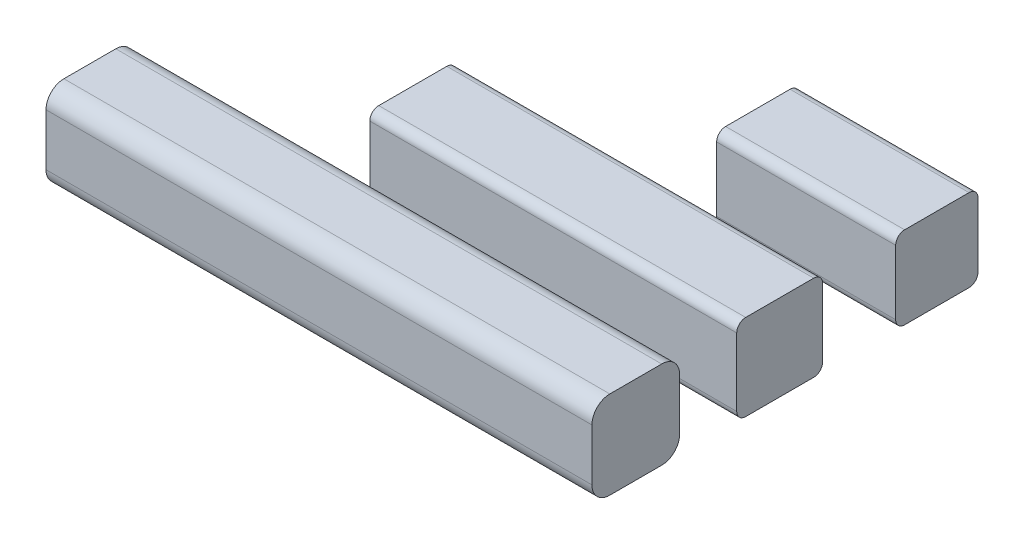
from build123d import *

# Parameters (mm, degrees)
SKETCH_1_R          = 4.9
SKETCH_1_W          = 5
SKETCH_1_H          = 5
EXTRUDE_1_DEPTH     = 5
SKETCH_2_W          = 10
SKETCH_2_H          = 5
EXTRUDE_2_DEPTH     = 5
SKETCH_3_R          = 5.914940822
CUT_EXTRUDE_1_DEPTH = 10
CUT_EXTRUDE_2_DEPTH = 10
SKETCH_5_W          = 4.8
SKETCH_5_H          = 4.8
EXTRUDE_3_DEPTH     = 10
SKETCH_5_W_2        = 4.6
SKETCH_5_H_2        = 4.6
EXTRUDE_3_2_DEPTH   = 10
SKETCH_5_W_3        = 4.5
SKETCH_5_H_3        = 4.5
EXTRUDE_3_3_DEPTH   = 10
FILLET_1_R          = 0.5
FILLET_2_R          = 0.5
FILLET_3_R          = 0.5
FILLET_4_R          = 0.5
SKETCH_6_W          = 4.9
SKETCH_6_H          = 4.9
EXTRUDE_4_DEPTH     = 20.5
FILLET_5_R          = 1
EXTRUDE_5_DEPTH     = 10.5
SKETCH_9_R          = 3.402598628
CUT_EXTRUDE_3_DEPTH = 10.5


with BuildPart() as part:
    # 草图1 → 凸台-拉伸1 (new body)
    with BuildSketch(Plane(origin=(0, 0, 0), x_dir=(1, 0, 0), z_dir=(0, 1, 0))):
        with Locations((-9.777161154, 17.932244479)):
            Circle(SKETCH_1_R)
        with Locations((-9.777161154, 17.932244479)):
            Rectangle(SKETCH_1_W, SKETCH_1_H, mode=Mode.SUBTRACT)
    extrude(amount=EXTRUDE_1_DEPTH)

    # 草图3 → 切除-拉伸1 (cut)
    with BuildSketch(Plane(origin=(0, 5, 0), x_dir=(1, 0, 0), z_dir=(0, 1, 0))):
        with Locations((-9.777161154, 17.932244479)):
            Circle(SKETCH_3_R)
    extrude(amount=-CUT_EXTRUDE_1_DEPTH, mode=Mode.SUBTRACT)


with BuildPart() as body_2:
    # 草图2 → 凸台-拉伸2 (new body)
    with BuildSketch(Plane(origin=(0, 0, 0), x_dir=(1, 0, 0), z_dir=(0, 1, 0))):
        with Locations((-15.49352073, 27.026927295)):
            Rectangle(SKETCH_2_W, SKETCH_2_H)
    extrude(amount=EXTRUDE_2_DEPTH)

    # 草图4 → 切除-拉伸2 (cut)
    with BuildSketch(Plane.ZY.offset(20.49352073)):
        Polygon((-29.526927295, 4.9), (-29.526927295, 5), (-24.526927295, 5), (-24.526927295, 0), (-24.626927295, 0), (-24.626927295, 4.9), align=None)
    extrude(amount=-CUT_EXTRUDE_2_DEPTH, mode=Mode.SUBTRACT)

    # 圆角1
    fillet_1_edges = [body_2.edges().sort_by_distance(p)[0] for p in [
        (-15.49352073, 0, -24.626927295),
        (-15.49352073, 4.9, -24.626927295),
        (-15.49352073, 4.9, -29.526927295),
        (-15.49352073, 0, -29.526927295),
    ]]
    fillet(fillet_1_edges, radius=FILLET_1_R)

    # 草图6 → 凸台-拉伸4 (add)
    with BuildSketch(Plane(origin=(-10.49352073, 0, 0), x_dir=(0, 0, -1), z_dir=(1, 0, 0))):
        with Locations((27.076927295, 2.45)):
            Rectangle(SKETCH_6_W, SKETCH_6_H)
    extrude(amount=EXTRUDE_4_DEPTH)

    # 圆角5
    fillet_5_edges = [body_2.edges().sort_by_distance(p)[0] for p in [
        (-0.24352073, 0, -24.626927295),
        (-0.24352073, 0, -29.526927295),
        (-0.24352073, 4.9, -29.526927295),
        (-0.24352073, 4.9, -24.626927295),
    ]]
    fillet(fillet_5_edges, radius=FILLET_5_R)


with BuildPart() as body_2_2:
    # 草图5 → 凸台-拉伸3 (new body)
    with BuildSketch(Plane(origin=(0, 0, 0), x_dir=(0, 0, -1), z_dir=(1, 0, 0))):
        with Locations((35.124788923, 2.4)):
            Rectangle(SKETCH_5_W, SKETCH_5_H)
    extrude(amount=EXTRUDE_3_DEPTH)

    # 圆角2
    fillet_2_edges = [body_2_2.edges().sort_by_distance(p)[0] for p in [
        (5, 4.8, -32.724788923),
        (5, 4.8, -37.524788923),
        (5, 0, -37.524788923),
        (5, 0, -32.724788923),
    ]]
    fillet(fillet_2_edges, radius=FILLET_2_R)

    # 草图8 → 凸台-拉伸5 (add)
    with BuildSketch(Plane.ZY):
        with BuildLine():
            Line((-33.224788923, 4.8), (-37.024788923, 4.8))
            ThreePointArc((-37.024788923, 4.8), (-37.378342314, 4.653553391), (-37.524788923, 4.3))
            Line((-37.524788923, 4.3), (-37.524788923, 0.5))
            ThreePointArc((-37.524788923, 0.5), (-37.378342314, 0.146446609), (-37.024788923, 0))
            Line((-37.024788923, 0), (-33.224788923, 0))
            ThreePointArc((-33.224788923, 0), (-32.871235532, 0.146446609), (-32.724788923, 0.5))
            Line((-32.724788923, 0.5), (-32.724788923, 4.3))
            ThreePointArc((-32.724788923, 4.3), (-32.871235532, 4.653553391), (-33.224788923, 4.8))
        make_face()
    extrude(amount=EXTRUDE_5_DEPTH)


with BuildPart() as body_3:
    # 草图5 → Extrude 3 2 (new body)
    with BuildSketch(Plane(origin=(0, 0, 0), x_dir=(0, 0, -1), z_dir=(1, 0, 0))):
        with Locations((43.904383403, 2.3)):
            Rectangle(SKETCH_5_W_2, SKETCH_5_H_2)
    extrude(amount=EXTRUDE_3_2_DEPTH)

    # 圆角3
    fillet_3_edges = [body_3.edges().sort_by_distance(p)[0] for p in [
        (5, 4.6, -41.604383403),
        (5, 4.6, -46.204383403),
        (5, 0, -46.204383403),
        (5, 0, -41.604383403),
    ]]
    fillet(fillet_3_edges, radius=FILLET_3_R)


with BuildPart() as body_4:
    # 草图5 → Extrude 3 3 (new body)
    with BuildSketch(Plane(origin=(0, 0, 0), x_dir=(0, 0, -1), z_dir=(1, 0, 0))):
        with Locations((50.920405069, 2.25)):
            Rectangle(SKETCH_5_W_3, SKETCH_5_H_3)
    extrude(amount=EXTRUDE_3_3_DEPTH)

    # 圆角4
    fillet_4_edges = [body_4.edges().sort_by_distance(p)[0] for p in [
        (5, 4.5, -48.670405069),
        (5, 4.5, -53.170405069),
        (5, 0, -53.170405069),
        (5, 0, -48.670405069),
    ]]
    fillet(fillet_4_edges, radius=FILLET_4_R)

    # 草图9 → 切除-拉伸3 (cut)
    with BuildSketch(Plane.ZY):
        with Locations((-50.9868081, 2.355561391)):
            Circle(SKETCH_9_R)
    extrude(amount=-CUT_EXTRUDE_3_DEPTH, mode=Mode.SUBTRACT)


solid = Compound([body_2.part, body_2_2.part, body_3.part])
